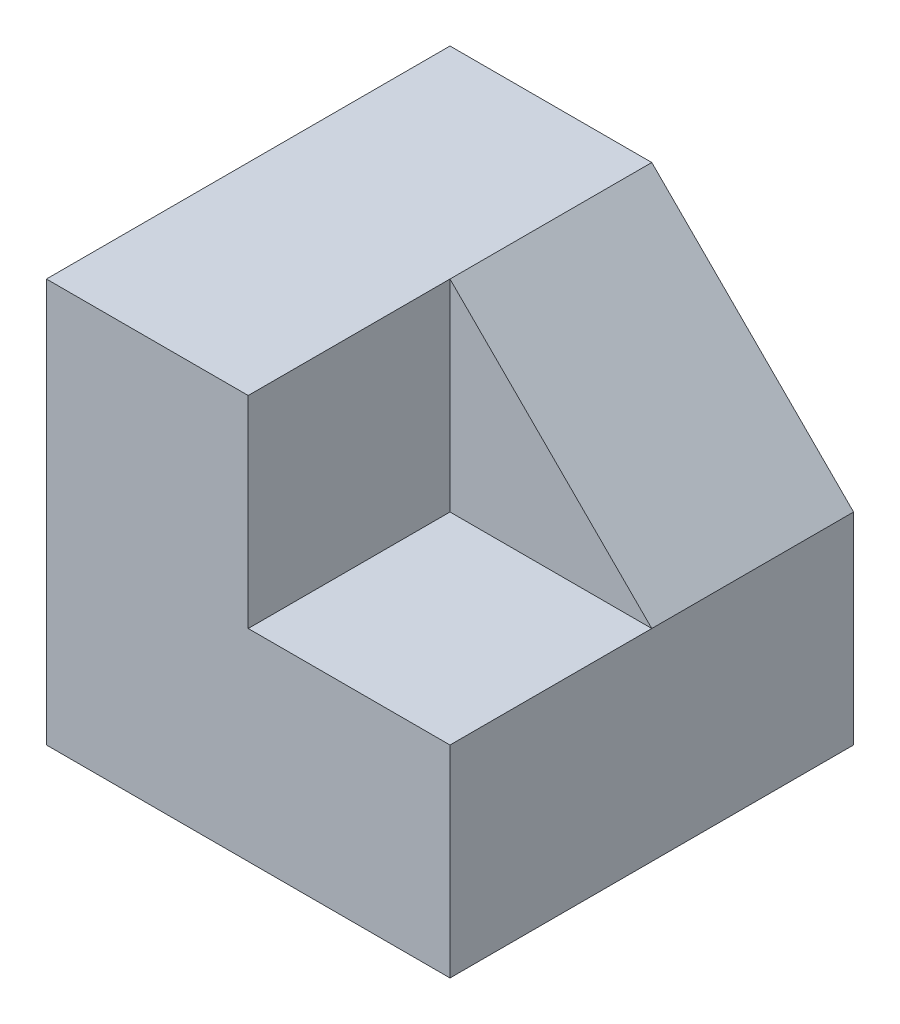
from build123d import *

# Parameters (mm, degrees)
SALIENTE_EXTRUIR1_DEPTH = 60
CORTAR_EXTRUIR1_DEPTH   = 30


with BuildPart() as part:
    # Croquis1 → Saliente-Extruir1 (new body)
    with BuildSketch(Plane.XY):
        Polygon((0, 0), (0, 60), (30, 60), (60, 30), (60, 0), align=None)
    extrude(amount=-SALIENTE_EXTRUIR1_DEPTH)

    # Croquis2 → Cortar-Extruir1 (cut)
    with BuildSketch(Plane.XY):
        Polygon((60, 30), (30, 60), (30, 30), align=None)
    extrude(amount=-CORTAR_EXTRUIR1_DEPTH, mode=Mode.SUBTRACT)


solid = part.part
